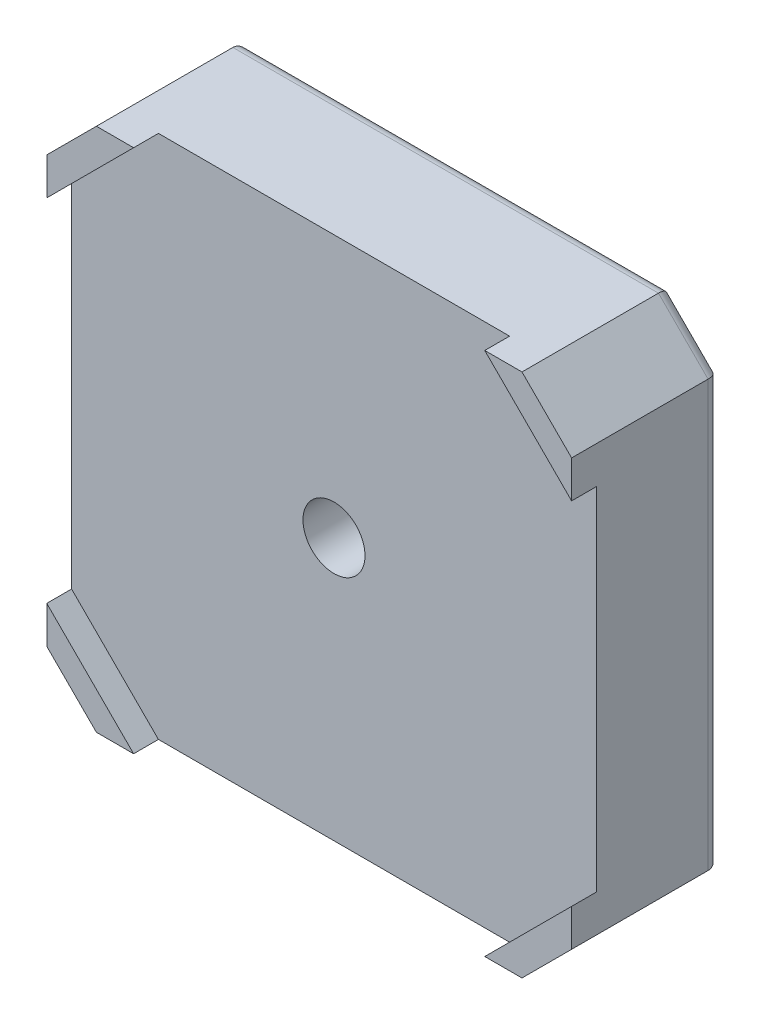
from build123d import *

# Parameters (mm, degrees)
BOSS_EXTRUDE1_DEPTH = 12
CUT_EXTRUDE1_DEPTH  = 2
SKETCH3_R           = 11
BOSS_EXTRUDE2_DEPTH = 2
SKETCH4_R           = 5.5
CUT_EXTRUDE2_DEPTH  = 7
SKETCH5_R           = 2.5
CUT_EXTRUDE3_DEPTH  = 8
FILLET1_R           = 1
FILLET2_R           = 0.5
SKETCH6_R           = 1.5
CUT_EXTRUDE4_DEPTH  = 3
FILLET3_R           = 0.5


with BuildPart() as part:
    # Sketch1 → Boss-Extrude1 (new body)
    with BuildSketch(Plane.XY):
        Polygon((-21.15, 17.15), (-17.15, 21.15), (17.15, 21.15), (21.15, 17.15), (21.15, -17.15), (17.15, -21.15), (-17.15, -21.15), (-21.15, -17.15), align=None)
    extrude(amount=BOSS_EXTRUDE1_DEPTH)

    # Sketch2 → Cut-Extrude1 (cut)
    with BuildSketch(Plane.XY.offset(12)):
        Polygon((-14.15, 21.15), (14.15, 21.15), (21.15, 14.15), (21.15, -14.15), (14.15, -21.15), (-14.15, -21.15), (-21.15, -14.15), (-21.15, 14.15), align=None)
    extrude(amount=-CUT_EXTRUDE1_DEPTH, mode=Mode.SUBTRACT)

    # Sketch3 → Boss-Extrude2 (add)
    with BuildSketch(Plane(origin=(0, 0, 0), x_dir=(-1, 0, 0), z_dir=(0, 0, -1))):
        Circle(SKETCH3_R)
    extrude(amount=BOSS_EXTRUDE2_DEPTH)

    # Sketch4 → Cut-Extrude2 (cut)
    with BuildSketch(Plane(origin=(0, 0, -2), x_dir=(-1, 0, 0), z_dir=(0, 0, -1))):
        Circle(SKETCH4_R)
    extrude(amount=-CUT_EXTRUDE2_DEPTH, mode=Mode.SUBTRACT)

    # Sketch5 → Cut-Extrude3 (cut, through all)
    with BuildSketch(Plane(origin=(0, 0, 5), x_dir=(-1, 0, 0), z_dir=(0, 0, -1))):
        Circle(SKETCH5_R)
    extrude(amount=-CUT_EXTRUDE3_DEPTH, mode=Mode.SUBTRACT)

    # Fillet1
    fillet1_edges = [part.edges().sort_by_distance(p)[0] for p in [
        (-19.15, -19.15, 0),
        (-21.15, 0, 0),
        (-19.15, 19.15, 0),
        (0, 21.15, 0),
        (19.15, 19.15, 0),
        (21.15, 0, 0),
        (19.15, -19.15, 0),
        (0, -21.15, 0),
    ]]
    fillet(fillet1_edges, radius=FILLET1_R)

    # Fillet2
    fillet2_edges = [part.edges().sort_by_distance(p)[0] for p in [
        (11, 0, -2),
        (5.5, 0, 5),
        (5.5, 0, -2),
    ]]
    fillet(fillet2_edges, radius=FILLET2_R)

    # Sketch6 → Cut-Extrude4 (cut)
    with BuildSketch(Plane(origin=(0, 0, 0), x_dir=(-1, 0, 0), z_dir=(0, 0, -1))):
        with Locations((-15.5, 15.5)):
            Circle(SKETCH6_R)
        with Locations((-15.5, -15.5)):
            Circle(SKETCH6_R)
        with Locations((15.5, -15.5)):
            Circle(SKETCH6_R)
        with Locations((15.5, 15.5)):
            Circle(SKETCH6_R)
    extrude(amount=-CUT_EXTRUDE4_DEPTH, mode=Mode.SUBTRACT)

    # Fillet3
    fillet3_edges = [part.edges().sort_by_distance(p)[0] for p in [
        (17, 15.5, 0),
        (17, -15.5, 0),
        (-14, -15.5, 0),
        (-14, 15.5, 0),
    ]]
    fillet(fillet3_edges, radius=FILLET3_R)


solid = part.part
